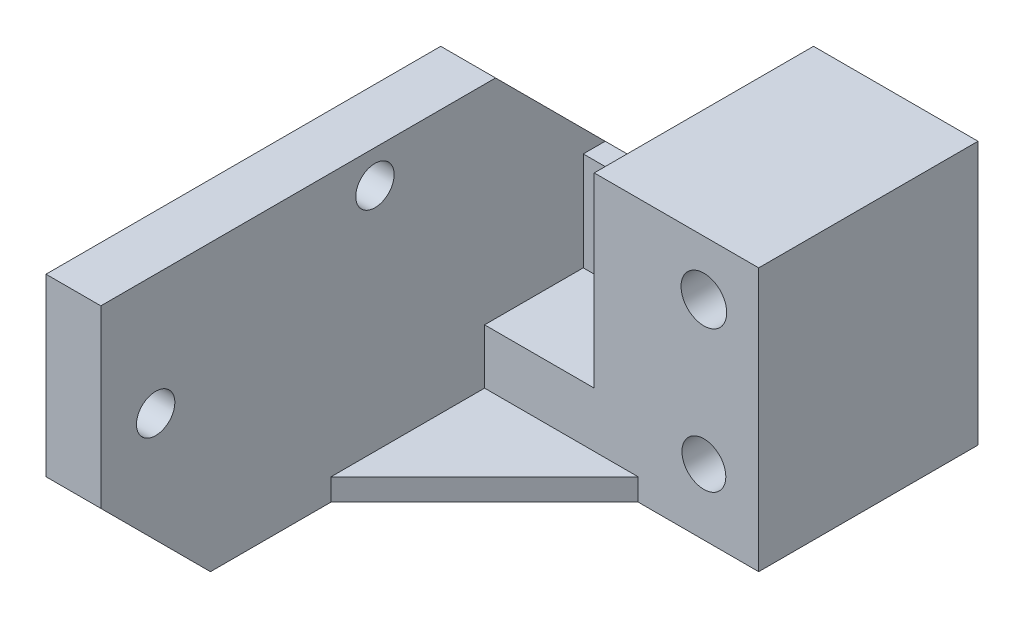
from build123d import *

# Parameters (mm, degrees)
EXTRUDE_1_DEPTH     = 12
CUT_EXTRUDE_1_REACH = 22
SKETCH_2_R          = 2
SKETCH_3_W          = 46
SKETCH_3_H          = 26
SKETCH_3_R          = 1.75
EXTRUDE_2_DEPTH     = 5
CHAMFER_1_SIZE      = 10
EXTRUDE_3_DEPTH     = 2
CHAMFER_2_SIZE      = 10
SKETCH_5_W          = 15
SKETCH_5_H          = 20
EXTRUDE_4_DEPTH     = 12
SKETCH_6_R          = 2.084127943
CUT_EXTRUDE_2_DEPTH = 21
SKETCH_7_W          = 10
SKETCH_7_H          = 5
CUT_EXTRUDE_3_DEPTH = 47
SKETCH_8_W          = 10
SKETCH_8_H          = 9
EXTRUDE_5_DEPTH     = 2
CHAMFER_3_SIZE      = 4


with BuildPart() as part:
    # Эскиз1 → Бобышка-Вытянуть1 (new body)
    with BuildSketch(Plane(origin=(0, 0, 0), x_dir=(1, 0, 0), z_dir=(0, 1, 0))):
        Polygon((0, 0), (0, 11), (15, 11), (15, 20), (30, 20), (30, 0), align=None)
    extrude(amount=EXTRUDE_1_DEPTH)

    # Эскиз2 → Вырез-Вытянуть1 (cut, up to next)
    with BuildSketch(Plane.XY, mode=Mode.PRIVATE) as cut_extrude_1_sk1:
        with Locations((25, 6)):
            Circle(SKETCH_2_R)
    cut_extrude_1_tool1 = extrude(cut_extrude_1_sk1.sketch, amount=-CUT_EXTRUDE_1_REACH, mode=Mode.PRIVATE) & part.part
    add(cut_extrude_1_tool1.solids().sort_by_distance((25, 6, 0))[0], mode=Mode.SUBTRACT)

    # Эскиз3 → Бобышка-Вытянуть2 (add)
    with BuildSketch(Plane.ZY):
        with Locations((12, 13)):
            Rectangle(SKETCH_3_W, SKETCH_3_H)
        with Locations((30, 15)):
            Circle(SKETCH_3_R, mode=Mode.SUBTRACT)
        with Locations((10, 23)):
            Circle(SKETCH_3_R, mode=Mode.SUBTRACT)
    extrude(amount=-EXTRUDE_2_DEPTH)

    # Фаска1
    chamfer_1_edges = [part.edges().sort_by_distance(p)[0] for p in [
        (2.5, 26, -11),
    ]]
    chamfer(chamfer_1_edges, length=CHAMFER_1_SIZE)

    # Эскиз4 → Бобышка-Вытянуть3 (add)
    with BuildSketch(Plane.XZ):
        Polygon((5, 14), (19, 0), (5, 0), align=None)
    extrude(amount=-EXTRUDE_3_DEPTH)

    # Фаска2
    chamfer_2_edges = [part.edges().sort_by_distance(p)[0] for p in [
        (2.5, 0, 35),
    ]]
    chamfer(chamfer_2_edges, length=CHAMFER_2_SIZE)

    # Эскиз5 → Бобышка-Вытянуть4 (add)
    with BuildSketch(Plane(origin=(0, 12, 0), x_dir=(1, 0, 0), z_dir=(0, 1, 0))):
        with Locations((22.5, 10)):
            Rectangle(SKETCH_5_W, SKETCH_5_H)
    extrude(amount=EXTRUDE_4_DEPTH)

    # Эскиз6 → Вырез-Вытянуть2 (cut, through all)
    with BuildSketch(Plane.XY):
        with Locations((25, 19)):
            Circle(SKETCH_6_R)
    extrude(amount=-CUT_EXTRUDE_2_DEPTH, mode=Mode.SUBTRACT)

    # Эскиз7 → Вырез-Вытянуть3 (cut, through all)
    with BuildSketch(Plane(origin=(0, 0, -11), x_dir=(-1, 0, 0), z_dir=(0, 0, -1))):
        with Locations((-10, 9.5)):
            Rectangle(SKETCH_7_W, SKETCH_7_H)
    extrude(amount=-CUT_EXTRUDE_3_DEPTH, mode=Mode.SUBTRACT)

    # Эскиз8 → Бобышка-Вытянуть5 (add)
    with BuildSketch(Plane(origin=(0, 0, -11), x_dir=(-1, 0, 0), z_dir=(0, 0, -1))):
        with Locations((-10, 11.5)):
            Rectangle(SKETCH_8_W, SKETCH_8_H)
    extrude(amount=-EXTRUDE_5_DEPTH)

    # Фаска3
    chamfer_3_edges = [part.edges().sort_by_distance(p)[0] for p in [
        (0, 8, -11),
        (7.5, 0, -11),
    ]]
    chamfer(chamfer_3_edges, length=CHAMFER_3_SIZE)


solid = part.part
